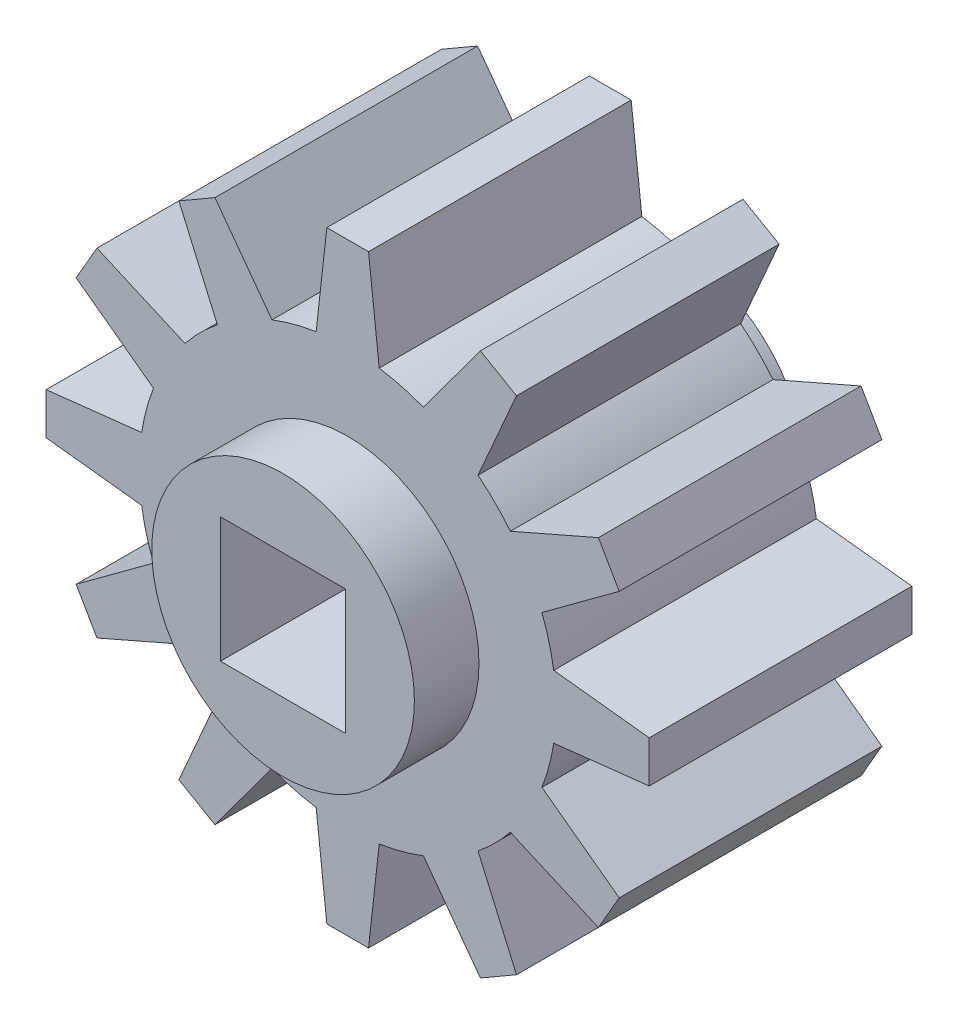
from build123d import *

# Parameters (mm, degrees)
SKETCH1_R           = 5
SKETCH1_W           = 3
SKETCH1_H           = 3
BOSS_EXTRUDE1_DEPTH = 6.3
SKETCH2_R           = 3.15
SKETCH2_W           = 3
SKETCH2_H           = 3
BOSS_EXTRUDE2_DEPTH = 1.55
SKETCH3_R           = 3.15
SKETCH3_W           = 3
SKETCH3_H           = 3
BOSS_EXTRUDE3_DEPTH = 1.55


with BuildPart() as part:
    # Sketch1 → Boss-Extrude1 (new body)
    with BuildSketch(Plane.XY):
        Circle(SKETCH1_R)
        Rectangle(SKETCH1_W, SKETCH1_H, mode=Mode.SUBTRACT)
        with BuildLine():
            ThreePointArc((-4.942448008, -0.756444105), (-5, 0), (-4.942448008, 0.756444105))
            Line((-4.942448008, 0.756444105), (-5, 0.75))
            Line((-5, 0.75), (-7.232738071, 0.5))
            Line((-7.232738071, 0.5), (-7.232738071, -0.5))
            Line((-7.232738071, -0.5), (-5, -0.75))
            Line((-5, -0.75), (-4.942448008, -0.756444105))
        make_face()
        with BuildLine():
            ThreePointArc((-4.658507585, 1.816124193), (-4.330127019, 2.5), (-3.90206348, 3.126323815))
            Line((-3.90206348, 3.126323815), (-3.955127019, 3.149519053))
            Line((-3.955127019, 3.149519053), (-6.013734908, 4.049381737))
            Line((-6.013734908, 4.049381737), (-6.513734908, 3.183356333))
            Line((-6.513734908, 3.183356333), (-4.705127019, 1.850480947))
            Line((-4.705127019, 1.850480947), (-4.658507585, 1.816124193))
        make_face()
        with BuildLine():
            ThreePointArc((-3.126323815, 3.90206348), (-2.5, 4.330127019), (-1.816124193, 4.658507585))
            Line((-1.816124193, 4.658507585), (-1.850480947, 4.705127019))
            Line((-1.850480947, 4.705127019), (-3.183356333, 6.513734908))
            Line((-3.183356333, 6.513734908), (-4.049381737, 6.013734908))
            Line((-4.049381737, 6.013734908), (-3.149519053, 3.955127019))
            Line((-3.149519053, 3.955127019), (-3.126323815, 3.90206348))
        make_face()
        with BuildLine():
            Line((0.5, 7.232738071), (-0.5, 7.232738071))
            Line((-0.5, 7.232738071), (-0.75, 5))
            Line((-0.75, 5), (-0.756444105, 4.942448008))
            ThreePointArc((-0.756444105, 4.942448008), (0, 5), (0.756444105, 4.942448008))
            Line((0.756444105, 4.942448008), (0.75, 5))
            Line((0.75, 5), (0.5, 7.232738071))
        make_face()
        with BuildLine():
            Line((1.850480947, 4.705127019), (1.816124193, 4.658507585))
            ThreePointArc((1.816124193, 4.658507585), (2.5, 4.330127019), (3.126323815, 3.90206348))
            Line((3.126323815, 3.90206348), (3.149519053, 3.955127019))
            Line((3.149519053, 3.955127019), (4.049381737, 6.013734908))
            Line((4.049381737, 6.013734908), (3.183356333, 6.513734908))
            Line((3.183356333, 6.513734908), (1.850480947, 4.705127019))
        make_face()
        with BuildLine():
            Line((3.955127019, 3.149519053), (3.90206348, 3.126323815))
            ThreePointArc((3.90206348, 3.126323815), (4.330127019, 2.5), (4.658507585, 1.816124193))
            Line((4.658507585, 1.816124193), (4.705127019, 1.850480947))
            Line((4.705127019, 1.850480947), (6.513734908, 3.183356333))
            Line((6.513734908, 3.183356333), (6.013734908, 4.049381737))
            Line((6.013734908, 4.049381737), (3.955127019, 3.149519053))
        make_face()
        with BuildLine():
            Line((5, 0.75), (4.942448008, 0.756444105))
            ThreePointArc((4.942448008, 0.756444105), (4.985591241, 0.379315144), (5, 0))
            ThreePointArc((5, 0), (4.985591241, -0.379315144), (4.942448008, -0.756444105))
            Line((4.942448008, -0.756444105), (5, -0.75))
            Line((5, -0.75), (7.232738071, -0.5))
            Line((7.232738071, -0.5), (7.232738071, 0.5))
            Line((7.232738071, 0.5), (5, 0.75))
        make_face()
        with BuildLine():
            Line((4.705127019, -1.850480947), (4.658507585, -1.816124193))
            ThreePointArc((4.658507585, -1.816124193), (4.330127019, -2.5), (3.90206348, -3.126323815))
            Line((3.90206348, -3.126323815), (3.955127019, -3.149519053))
            Line((3.955127019, -3.149519053), (6.013734908, -4.049381737))
            Line((6.013734908, -4.049381737), (6.513734908, -3.183356333))
            Line((6.513734908, -3.183356333), (4.705127019, -1.850480947))
        make_face()
        with BuildLine():
            Line((3.149519053, -3.955127019), (3.126323815, -3.90206348))
            ThreePointArc((3.126323815, -3.90206348), (2.5, -4.330127019), (1.816124193, -4.658507585))
            Line((1.816124193, -4.658507585), (1.850480947, -4.705127019))
            Line((1.850480947, -4.705127019), (3.183356333, -6.513734908))
            Line((3.183356333, -6.513734908), (4.049381737, -6.013734908))
            Line((4.049381737, -6.013734908), (3.149519053, -3.955127019))
        make_face()
        with BuildLine():
            ThreePointArc((0.756444105, -4.942448008), (0, -5), (-0.756444105, -4.942448008))
            Line((-0.756444105, -4.942448008), (-0.75, -5))
            Line((-0.75, -5), (-0.5, -7.232738071))
            Line((-0.5, -7.232738071), (0.5, -7.232738071))
            Line((0.5, -7.232738071), (0.75, -5))
            Line((0.75, -5), (0.756444105, -4.942448008))
        make_face()
        with BuildLine():
            ThreePointArc((-1.816124193, -4.658507585), (-2.5, -4.330127019), (-3.126323815, -3.90206348))
            Line((-3.126323815, -3.90206348), (-3.149519053, -3.955127019))
            Line((-3.149519053, -3.955127019), (-4.049381737, -6.013734908))
            Line((-4.049381737, -6.013734908), (-3.183356333, -6.513734908))
            Line((-3.183356333, -6.513734908), (-1.850480947, -4.705127019))
            Line((-1.850480947, -4.705127019), (-1.816124193, -4.658507585))
        make_face()
        with BuildLine():
            ThreePointArc((-3.90206348, -3.126323815), (-4.330127019, -2.5), (-4.658507585, -1.816124193))
            Line((-4.658507585, -1.816124193), (-4.705127019, -1.850480947))
            Line((-4.705127019, -1.850480947), (-6.513734908, -3.183356333))
            Line((-6.513734908, -3.183356333), (-6.013734908, -4.049381737))
            Line((-6.013734908, -4.049381737), (-3.955127019, -3.149519053))
            Line((-3.955127019, -3.149519053), (-3.90206348, -3.126323815))
        make_face()
    extrude(amount=BOSS_EXTRUDE1_DEPTH)

    # Sketch2 → Boss-Extrude2 (add)
    with BuildSketch(Plane.XY.offset(6.3)):
        Circle(SKETCH2_R)
        Rectangle(SKETCH2_W, SKETCH2_H, mode=Mode.SUBTRACT)
    extrude(amount=BOSS_EXTRUDE2_DEPTH)

    # Sketch3 → Boss-Extrude3 (add)
    with BuildSketch(Plane(origin=(0, 0, 0), x_dir=(-1, 0, 0), z_dir=(0, 0, -1))):
        Circle(SKETCH3_R)
        Rectangle(SKETCH3_W, SKETCH3_H, mode=Mode.SUBTRACT)
    extrude(amount=BOSS_EXTRUDE3_DEPTH)


solid = part.part
